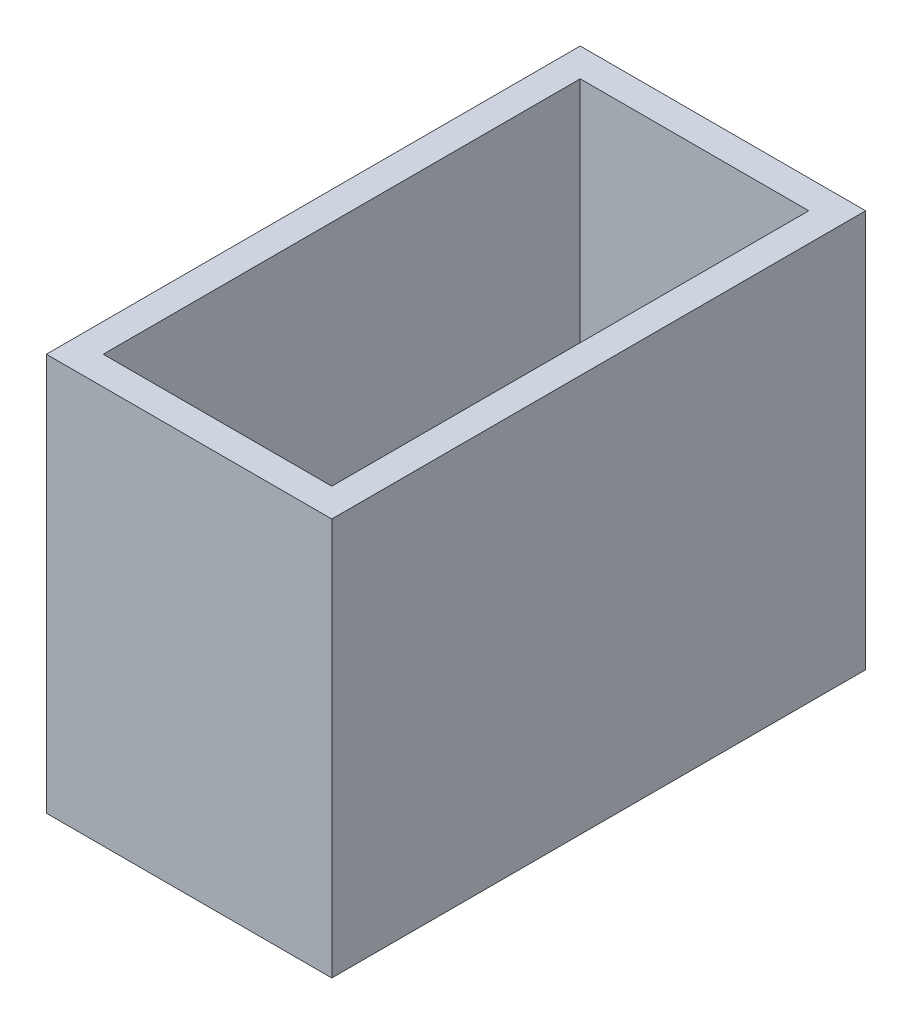
from build123d import *

# Parameters (mm, degrees)
SKETCH1_W           = 14.36
SKETCH1_H           = 26.86
SKETCH1_W_2         = 11.5
SKETCH1_H_2         = 24
BOSS_EXTRUDE1_DEPTH = 20


with BuildPart() as part:
    # Sketch1 → Boss-Extrude1 (new body)
    with BuildSketch(Plane(origin=(0, 0, 0), x_dir=(1, 0, 0), z_dir=(0, 1, 0))):
        Rectangle(SKETCH1_W, SKETCH1_H)
        Rectangle(SKETCH1_W_2, SKETCH1_H_2, mode=Mode.SUBTRACT)
    extrude(amount=BOSS_EXTRUDE1_DEPTH)


solid = part.part
